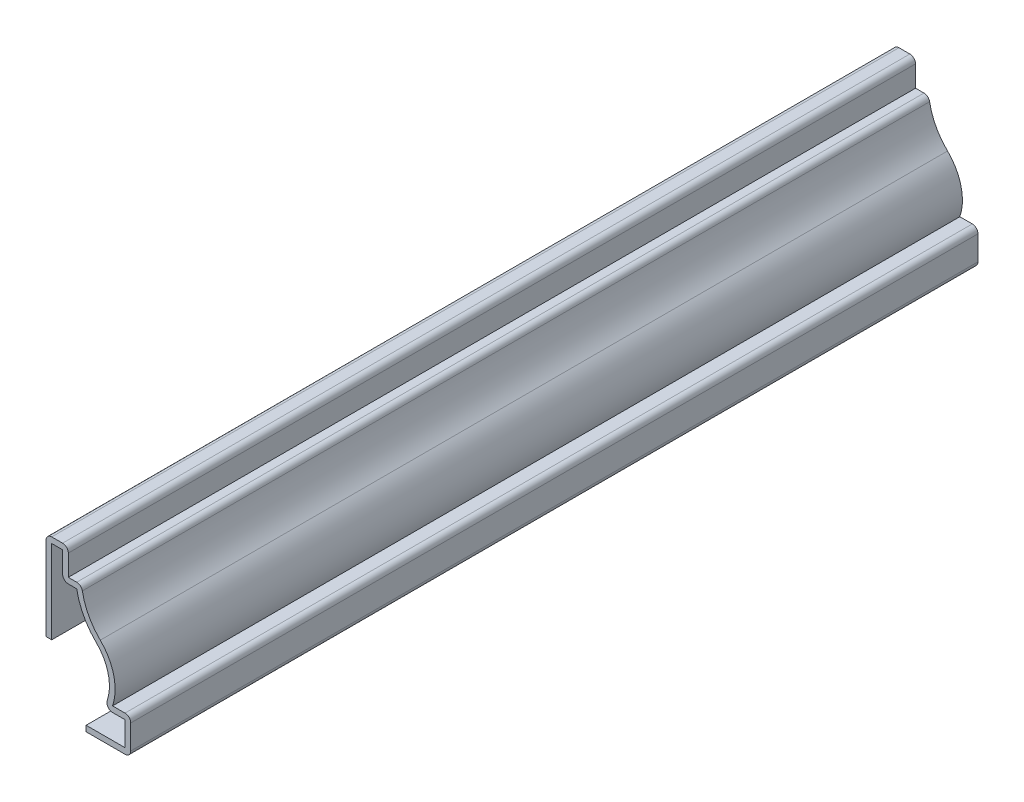
from build123d import *

# Parameters (mm, degrees)
EXTRUDE_THIN1_DEPTH = 150.8125
FILLET1_R           = 1.016


with BuildPart() as part:
    # Sketch1 → Extrude-Thin1 (new body)
    with BuildSketch(Plane.XY):
        with BuildLine():
            Line((11.90625, 0), (19.84375, 0))
            Line((19.84375, 0), (19.84375, 6.35))
            Line((19.84375, 6.35), (16.611859403, 6.35))
            ThreePointArc((16.611859403, 6.35), (16.819864191, 11.185113028), (14.420873366, 15.388257922))
            ThreePointArc((14.420873366, 15.388257922), (12.164462393, 18.51520612), (11.1125, 22.225))
            Line((11.1125, 22.225), (8.73125, 22.225))
            Line((8.73125, 22.225), (8.73125, 26.9875))
            Line((8.73125, 26.9875), (4.7625, 26.9875))
            Line((4.7625, 26.9875), (4.7625, 11.1125))
            Line((4.7625, 11.1125), (5.7785, 11.1125))
            Line((5.7785, 11.1125), (5.7785, 25.9715))
            Line((5.7785, 25.9715), (7.71525, 25.9715))
            Line((7.71525, 25.9715), (7.71525, 21.209))
            Line((7.71525, 21.209), (10.230316486, 21.209))
            ThreePointArc((10.230316486, 21.209), (11.458524166, 17.661660911), (13.712626283, 14.659806091))
            ThreePointArc((13.712626283, 14.659806091), (15.971237356, 10.225128152), (15.052239099, 5.334))
            Line((15.052239099, 5.334), (18.82775, 5.334))
            Line((18.82775, 5.334), (18.82775, 1.016))
            Line((18.82775, 1.016), (11.90625, 1.016))
            Line((11.90625, 1.016), (11.90625, 0))
        make_face()
    extrude(amount=-EXTRUDE_THIN1_DEPTH)

    # Fillet1
    fillet1_edges = [part.edges().sort_by_distance(p)[0] for p in [
        (4.7625, 26.9875, -75.40625),
        (8.73125, 26.9875, -75.40625),
        (11.1125, 22.225, -75.40625),
        (19.84375, 6.35, -75.40625),
        (19.84375, 0, -75.40625),
        (15.052239099, 5.334, -75.40625),
        (7.71525, 21.209, -75.40625),
    ]]
    fillet(fillet1_edges, radius=FILLET1_R)


solid = part.part
